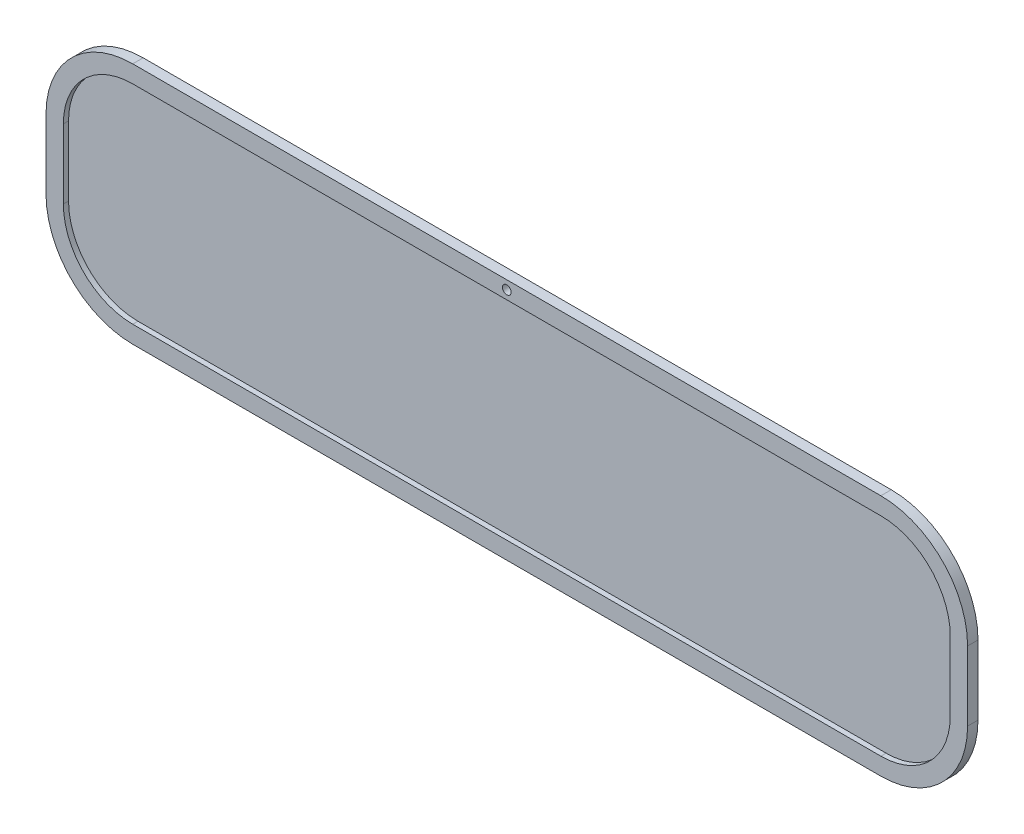
from build123d import *

# Parameters (mm, degrees)
AUFSATZ_LINEAR_AUSTRAGEN1_DEPTH = 3
SKIZZE2_W                       = 52.543234094
SKIZZE2_H                       = 140
SKIZZE2_W_2                     = 111.276179835
AUFSATZ_LINEAR_AUSTRAGEN2_DEPTH = 3
VERRUNDUNG1_R                   = 50
VERRUNDUNG2_R                   = 50
SKIZZE3_R                       = 2.5
SCHNITT_LINEAR_AUSTRAGEN1_DEPTH = 10
AUFSATZ_LINEAR_AUSTRAGEN3_DEPTH = 3
SKIZZE6_R                       = 2.5
SCHNITT_LINEAR_AUSTRAGEN2_DEPTH = 7


with BuildPart() as part:
    # Skizze1 → Aufsatz-Linear austragen1 (new body)
    with BuildSketch(Plane.XY):
        Polygon((432.051221513, 126.172344807), (432.051221513, 206.172344807), (431.494421695, 212.025054468), (429.845419749, 217.652847778), (427.167585893, 222.839451798), (423.563827781, 227.385548243), (419.172635816, 231.116433176), (414.162761042, 233.888730783), (408.726730139, 235.595903219), (403.073446724, 236.172344807), (-70.230208158, 236.172344807), (-75.883491573, 235.595903219), (-81.319522476, 233.888730783), (-86.32939725, 231.116433176), (-90.720589215, 227.385548243), (-94.324347327, 222.839451798), (-97.002181183, 217.652847778), (-98.651183129, 212.025054468), (-99.207982946, 206.172344807), (-99.207982946, 126.172344807), (-98.651183129, 120.319635147), (-97.002181183, 114.691841836), (-94.324347327, 109.505237817), (-90.720589215, 104.959141372), (-86.32939725, 101.228256438), (-81.319522476, 98.455958832), (-75.883491573, 96.748786395), (-70.230208158, 96.172344807), (403.073446724, 96.172344807), (408.726730139, 96.748786395), (414.162761042, 98.455958832), (419.172635816, 101.228256438), (423.563827781, 104.959141372), (427.167585893, 109.505237817), (429.845419749, 114.691841836), (431.494421695, 120.319635147), align=None)
    extrude(amount=AUFSATZ_LINEAR_AUSTRAGEN1_DEPTH)

    # Skizze2 → Aufsatz-Linear austragen2 (add)
    with BuildSketch(Plane(origin=(0, 0, 0), x_dir=(-1, 0, 0), z_dir=(0, 0, -1))):
        with Locations((-405.779604466, 166.172344807)):
            Rectangle(SKIZZE2_W, SKIZZE2_H)
        with Locations((43.569893028, 166.172344807)):
            Rectangle(SKIZZE2_W_2, SKIZZE2_H)
    extrude(amount=-AUFSATZ_LINEAR_AUSTRAGEN2_DEPTH)

    # Verrundung1
    verrundung1_edges = [part.edges().sort_by_distance(p)[0] for p in [
        (432.051221513, 96.172344807, 1.5),
        (-99.207982946, 236.172344807, 1.5),
        (-99.207982946, 96.172344807, 1.5),
    ]]
    fillet(verrundung1_edges, radius=VERRUNDUNG1_R)

    # Verrundung2
    verrundung2_edges = [part.edges().sort_by_distance(p)[0] for p in [
        (432.051221513, 236.172344807, 1.5),
    ]]
    fillet(verrundung2_edges, radius=VERRUNDUNG2_R)

    # Skizze3 → Schnitt-Linear austragen1 (cut)
    with BuildSketch(Plane.XY.offset(3)):
        with Locations((166.421619283, 231.172344807)):
            Circle(SKIZZE3_R)
    extrude(amount=-SCHNITT_LINEAR_AUSTRAGEN1_DEPTH, mode=Mode.SUBTRACT)

    # Skizze5 → Aufsatz-Linear austragen3 (add)
    with BuildSketch(Plane.XY.offset(3)):
        with BuildLine():
            Line((432.051221513, 146.172344807), (432.051221513, 186.172344807))
            ThreePointArc((432.051221513, 186.172344807), (417.406560572, 221.527683867), (382.051221513, 236.172344807))
            Line((382.051221513, 236.172344807), (-49.207982946, 236.172344807))
            ThreePointArc((-49.207982946, 236.172344807), (-84.563322006, 221.527683867), (-99.207982946, 186.172344807))
            Line((-99.207982946, 186.172344807), (-99.207982946, 146.172344807))
            ThreePointArc((-99.207982946, 146.172344807), (-84.563322006, 110.817005748), (-49.207982946, 96.172344807))
            Line((-49.207982946, 96.172344807), (382.051221513, 96.172344807))
            ThreePointArc((382.051221513, 96.172344807), (417.406560572, 110.817005748), (432.051221513, 146.172344807))
        make_face()
        with BuildLine():
            Line((-89.207982946, 186.172344807), (-89.207982946, 146.172344807))
            ThreePointArc((-89.207982946, 146.172344807), (-77.492254194, 117.88807356), (-49.207982946, 106.172344807))
            Line((-49.207982946, 106.172344807), (382.051221513, 106.172344807))
            ThreePointArc((382.051221513, 106.172344807), (410.33549276, 117.88807356), (422.051221513, 146.172344807))
            Line((422.051221513, 146.172344807), (422.051221513, 186.172344807))
            ThreePointArc((422.051221513, 186.172344807), (410.33549276, 214.456616055), (382.051221513, 226.172344807))
            Line((382.051221513, 226.172344807), (-49.207982946, 226.172344807))
            ThreePointArc((-49.207982946, 226.172344807), (-77.492254194, 214.456616055), (-89.207982946, 186.172344807))
        make_face(mode=Mode.SUBTRACT)
    extrude(amount=AUFSATZ_LINEAR_AUSTRAGEN3_DEPTH)

    # Skizze6 → Schnitt-Linear austragen2 (cut, through all)
    with BuildSketch(Plane(origin=(0, 0, 0), x_dir=(-1, 0, 0), z_dir=(0, 0, -1))):
        with Locations(Location((-166.421619283, 231.172344807, 0), (0, 0, 180))):  # turned: the seam where the file's is
            Circle(SKIZZE6_R)
    extrude(amount=-SCHNITT_LINEAR_AUSTRAGEN2_DEPTH, mode=Mode.SUBTRACT)


solid = part.part
